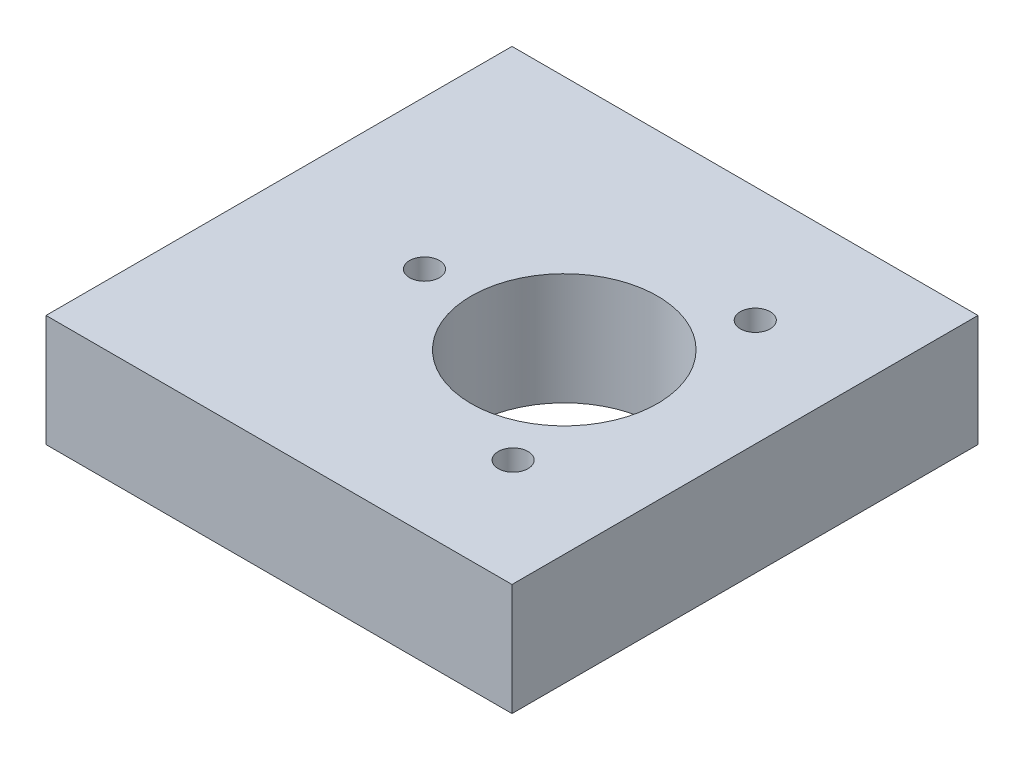
from build123d import *

# Parameters (mm, degrees)
SKETCH_1_W             = 50
SKETCH_1_H             = 12
EXTRUDE_1_DEPTH        = 50
HOLE_WIZARD_M4_1_D     = 3.3
HOLE_WIZARD_M4_1_DEPTH = 10.1
HOLE_WIZARD_M4_1_TIP   = 0.991420021
SKETCH_5_R             = 10
SKETCH_5_R_2           = 1.6
CUT_EXTRUDE_1_DEPTH    = 50


with BuildPart() as part:
    # 草图1 → 凸台-拉伸1 (new body)
    with BuildSketch(Plane.XY):
        with Locations((-1.474142426, -7.925704975)):
            Rectangle(SKETCH_1_W, SKETCH_1_H)
    extrude(amount=EXTRUDE_1_DEPTH)

    # M4 螺纹孔1
    with Locations(Plane(origin=(0, 0, 0), x_dir=(-1, 0, 0), z_dir=(0, 0, -1))):
        with Locations((-4.525857574, -7.925704975), (14.474142426, -7.925704975)):
            Hole(HOLE_WIZARD_M4_1_D / 2, depth=HOLE_WIZARD_M4_1_DEPTH)
            with Locations((0, 0, -(HOLE_WIZARD_M4_1_DEPTH + HOLE_WIZARD_M4_1_TIP / 2))):  # 118° drill point
                Cone(0, HOLE_WIZARD_M4_1_D / 2, HOLE_WIZARD_M4_1_TIP, mode=Mode.SUBTRACT)

    # 草图5 → 切除-拉伸1 (cut)
    with BuildSketch(Plane(origin=(0, -1.925704975, 0), x_dir=(1, 0, 0), z_dir=(0, 1, 0))):
        with Locations((4.525857574, -25.389445239)):
            Circle(SKETCH_5_R)
        with Locations((12.025857574, -12.399064182)):
            Circle(SKETCH_5_R_2)
        with Locations((12.025857574, -38.379826296)):
            Circle(SKETCH_5_R_2)
        with Locations((-10.474142426, -25.389445239)):
            Circle(SKETCH_5_R_2)
    extrude(amount=-CUT_EXTRUDE_1_DEPTH, mode=Mode.SUBTRACT)


solid = part.part
